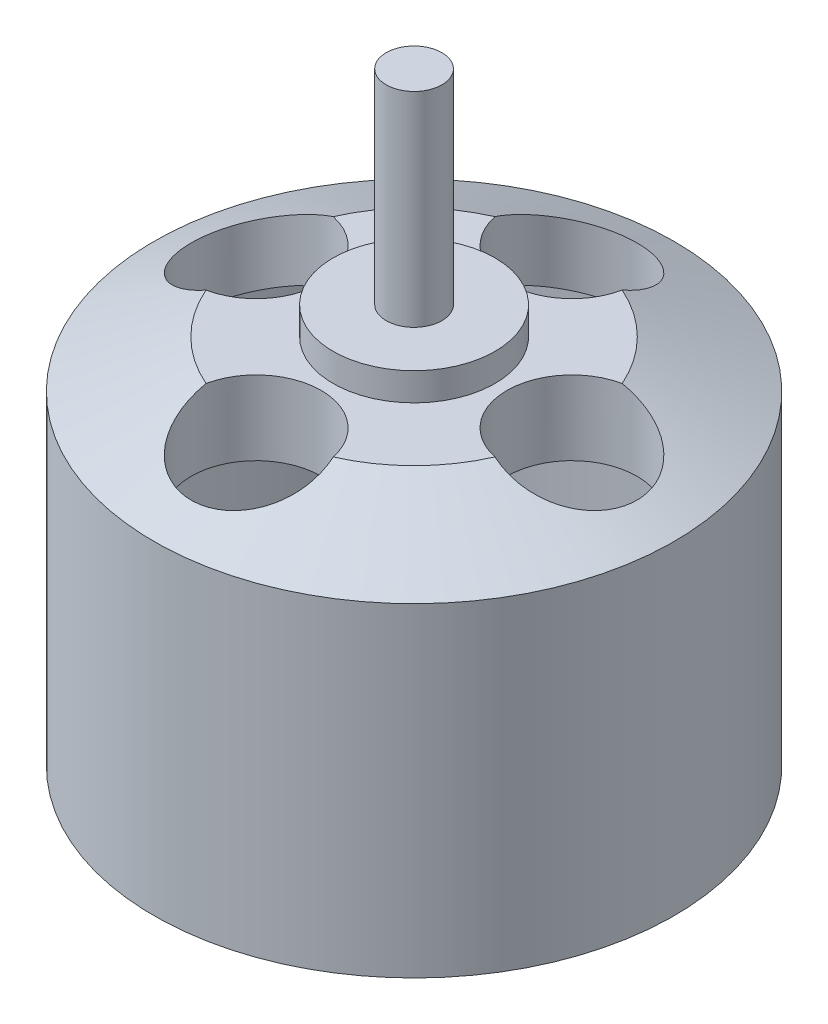
from build123d import *

# Parameters (mm, degrees)
CROQUIS1_W            = 1.5
CROQUIS1_H            = 11
CROQUIS2_R            = 3.5
CORTAR_EXTRUIR1_DEPTH = 7


with BuildPart() as part:
    # Croquis1 → Revolución1 (revolve)
    with BuildSketch(Plane.XY):
        Polygon((-13.24, -16), (-14, -16), (-14, 1.453703704), (-8.5, 4), (-4.36, 4), (-4.36, 5.5), (0, 5.5), (0, 0), (-10, 0), (-13.24, -1.5), align=None)
        with Locations((-0.75, 11)):
            Rectangle(CROQUIS1_W, CROQUIS1_H)
    revolve(axis=Axis((0, -19.446999562, 0), (0, 1, 0)))

    # Croquis2 → Cortar-Extruir1 (cut)
    with BuildSketch(Plane(origin=(0, 4, 0), x_dir=(1, 0, 0), z_dir=(0, 1, 0))):
        with Locations((0, 8.5)):
            Circle(CROQUIS2_R)
        with Locations((8.5, 0)):
            Circle(CROQUIS2_R)
        with Locations((0, -8.5)):
            Circle(CROQUIS2_R)
        with Locations((-8.5, 0)):
            Circle(CROQUIS2_R)
    extrude(amount=-CORTAR_EXTRUIR1_DEPTH, mode=Mode.SUBTRACT)


solid = part.part
